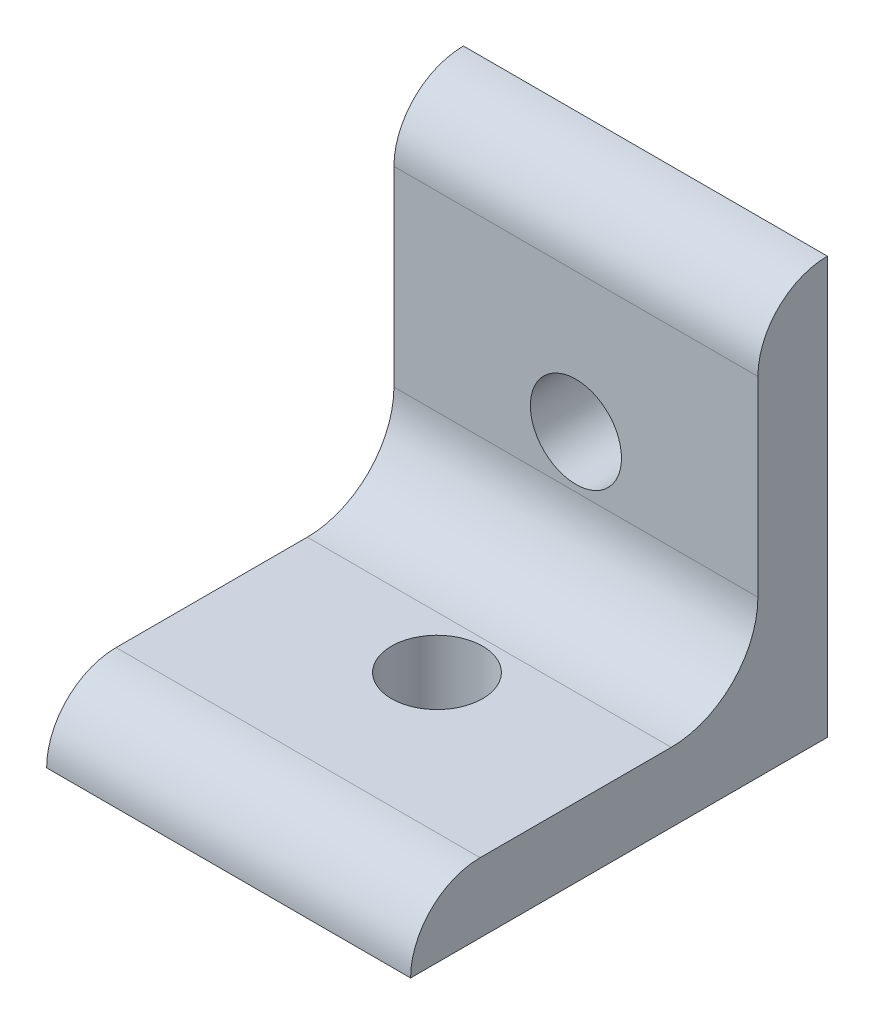
from build123d import *

# Parameters (mm, degrees)
BOSS_EXTRUDE1_DEPTH = 33.274
HOLE1_D             = 8.3312
HOLE1_DEPTH         = 6.35
HOLE2_D             = 8.3312
HOLE2_DEPTH         = 6.35
FILLET1_R           = 7.9248


with BuildPart() as part:
    # Sketch1 → Boss-Extrude1 (new body)
    with BuildSketch(Plane(origin=(16.637, 0, 0), x_dir=(0, 0, -1), z_dir=(1, 0, 0))):
        with BuildLine():
            Line((-38.1, 0), (0, 0))
            Line((0, 0), (0, 38.1))
            ThreePointArc((0, 38.1), (-4.490128061, 36.240128061), (-6.35, 31.75))
            Line((-6.35, 31.75), (-6.35, 6.35))
            Line((-6.35, 6.35), (-31.75, 6.35))
            ThreePointArc((-31.75, 6.35), (-36.240128061, 4.490128061), (-38.1, 0))
        make_face()
    extrude(amount=-BOSS_EXTRUDE1_DEPTH)

    # Hole1
    with Locations(Plane.XY.offset(6.35)):
        with Locations((0, 19.05)):
            Hole(HOLE1_D / 2, depth=HOLE1_DEPTH)

    # Hole2
    with Locations(Plane(origin=(0, 6.35, 0), x_dir=(1, 0, 0), z_dir=(0, 1, 0))):
        with Locations((0, -19.05)):
            Hole(HOLE2_D / 2, depth=HOLE2_DEPTH)

    # Fillet1
    fillet1_edges = [part.edges().sort_by_distance(p)[0] for p in [
        (0, 6.35, 6.35),
    ]]
    fillet(fillet1_edges, radius=FILLET1_R)


solid = part.part
